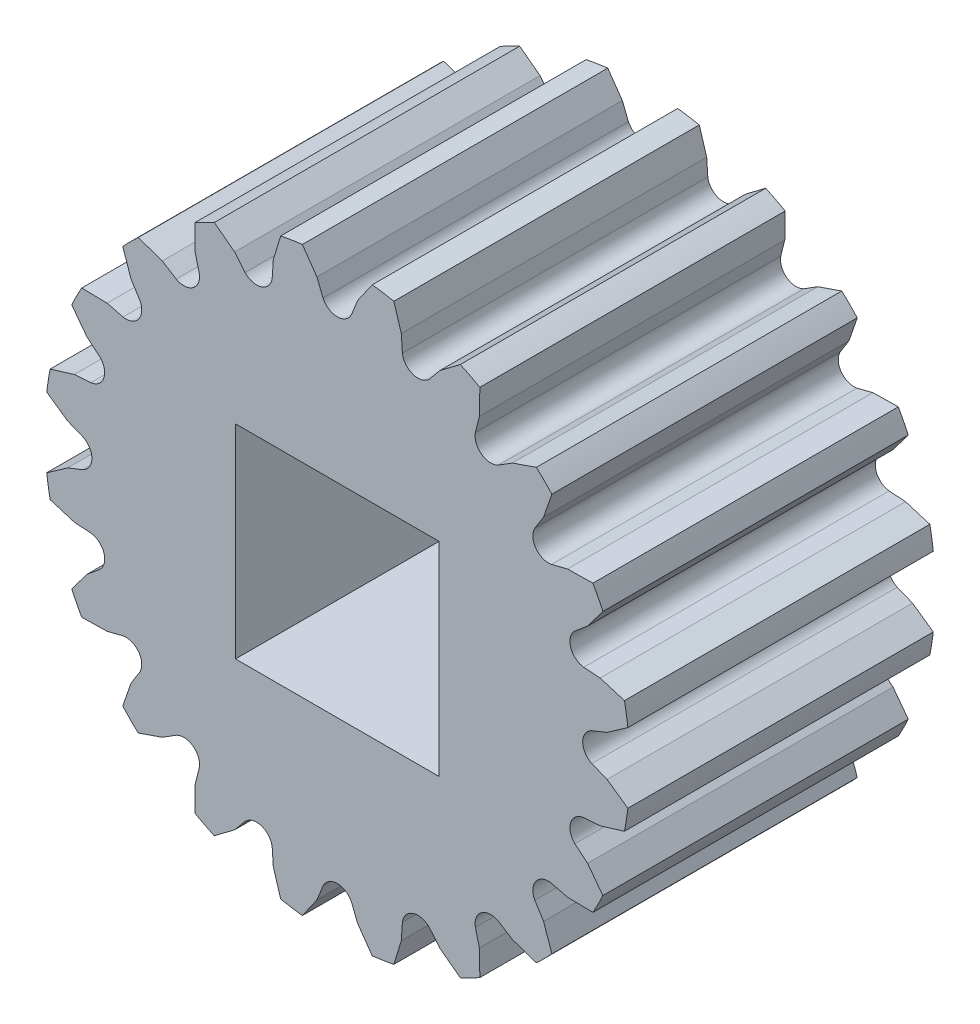
from build123d import *

# Parameters (mm, degrees)
SKETCH1_R           = 11.5
SKETCH1_W           = 8
SKETCH1_H           = 8
BOSS_EXTRUDE1_DEPTH = 12
CUT_EXTRUDE1_DEPTH  = 12
CIRPATTERN1_COUNT   = 20


with BuildPart() as part:
    # Sketch1 → Boss-Extrude1 (new body)
    with BuildSketch(Plane.XY):
        Circle(SKETCH1_R)
        Rectangle(SKETCH1_W, SKETCH1_H, mode=Mode.SUBTRACT)
    extrude(amount=BOSS_EXTRUDE1_DEPTH)

    # Sketch2 → Cut-Extrude1 (cut)
    with BuildSketch(Plane.XY.offset(12)):
        with BuildLine():
            Line((0, 11.6), (1.5, 11.6))
            Line((1.5, 11.6), (0.8, 10.6))
            Line((0.8, 10.6), (0.559317479, 10))
            ThreePointArc((0.559317479, 10), (0, 9.642447684), (-0.559317479, 10))
            Line((-0.559317479, 10), (-0.8, 10.6))
            Line((-0.8, 10.6), (-1.5, 11.6))
            Line((-1.5, 11.6), (0, 11.6))
        make_face()
    cut_extrude1 = extrude(amount=-CUT_EXTRUDE1_DEPTH, mode=Mode.SUBTRACT)

    # CirPattern1: Cut-Extrude1 ×20 about axis
    cirpattern1_axis = Axis((0, 0, 0), (0, 0, 1))
    for i in range(1, CIRPATTERN1_COUNT):
        add(cut_extrude1.rotate(cirpattern1_axis, i * 360 / CIRPATTERN1_COUNT), mode=Mode.SUBTRACT)


solid = part.part
